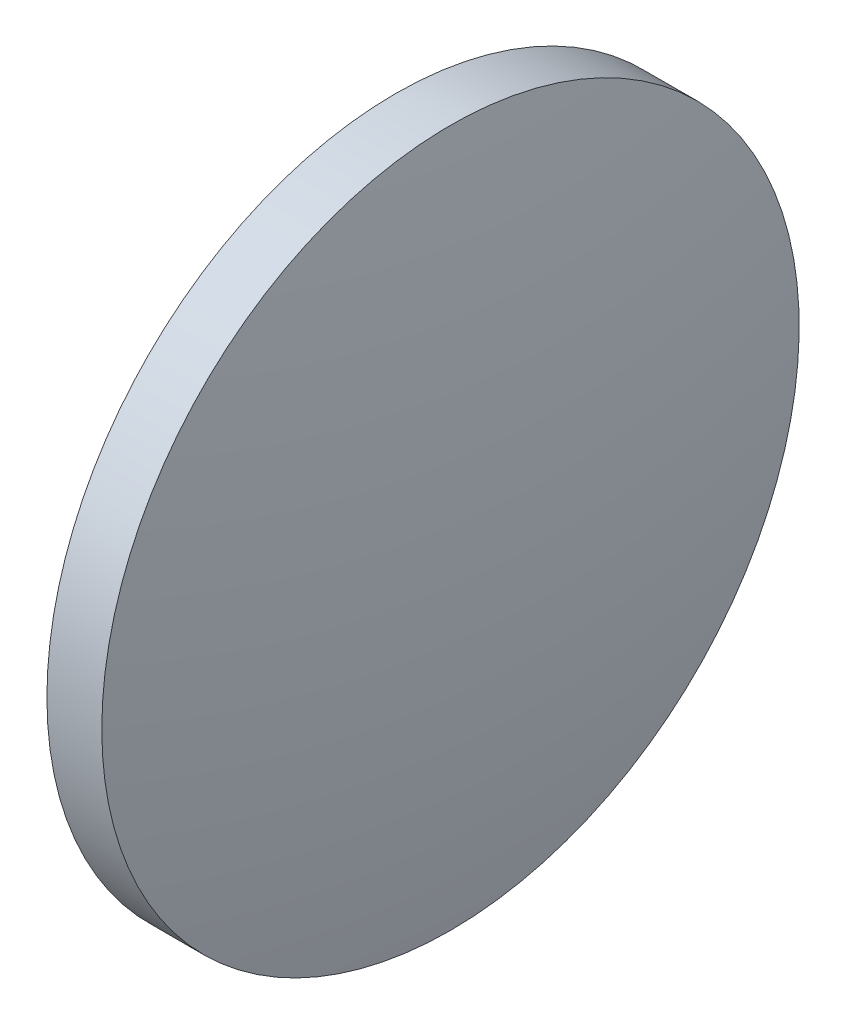
from build123d import *

# Parameters (mm, degrees)
SKETCH_1_ONE_SIDE_W = 1.999342857
SKETCH_1_ONE_SIDE_H = 12.7


with BuildPart() as part:
    # 草图1 one side → 旋转1 (revolve)
    with BuildSketch(Plane.XY, mode=Mode.PRIVATE) as revolve_1_sk:
        with Locations((86.458193775, 54.966113023)):
            Rectangle(SKETCH_1_ONE_SIDE_W, SKETCH_1_ONE_SIDE_H)
        with BuildLine():
            Line((84.308228918, 48.616113023), (85.458522346, 48.616113023))
            Line((85.458522346, 48.616113023), (85.458522346, 61.316113023))
            ThreePointArc((85.458522346, 61.316113023), (84.596389659, 54.992106573), (84.308228918, 48.616113023))
        make_face()
        with BuildLine():
            Line((87.457865203, 48.616113023), (88.608158632, 48.616113023))
            ThreePointArc((88.608158632, 48.616113023), (88.31999789, 54.992106573), (87.457865203, 61.316113023))
            Line((87.457865203, 61.316113023), (87.457865203, 48.616113023))
        make_face()
    revolve(revolve_1_sk.sketch.rotate(Axis((79.305401351, 48.616113023, 0), (1, 0, 0)), 90), axis=Axis((79.305401351, 48.616113023, 0), (1, 0, 0)))  # turned: the seam where the file's is


solid = part.part
